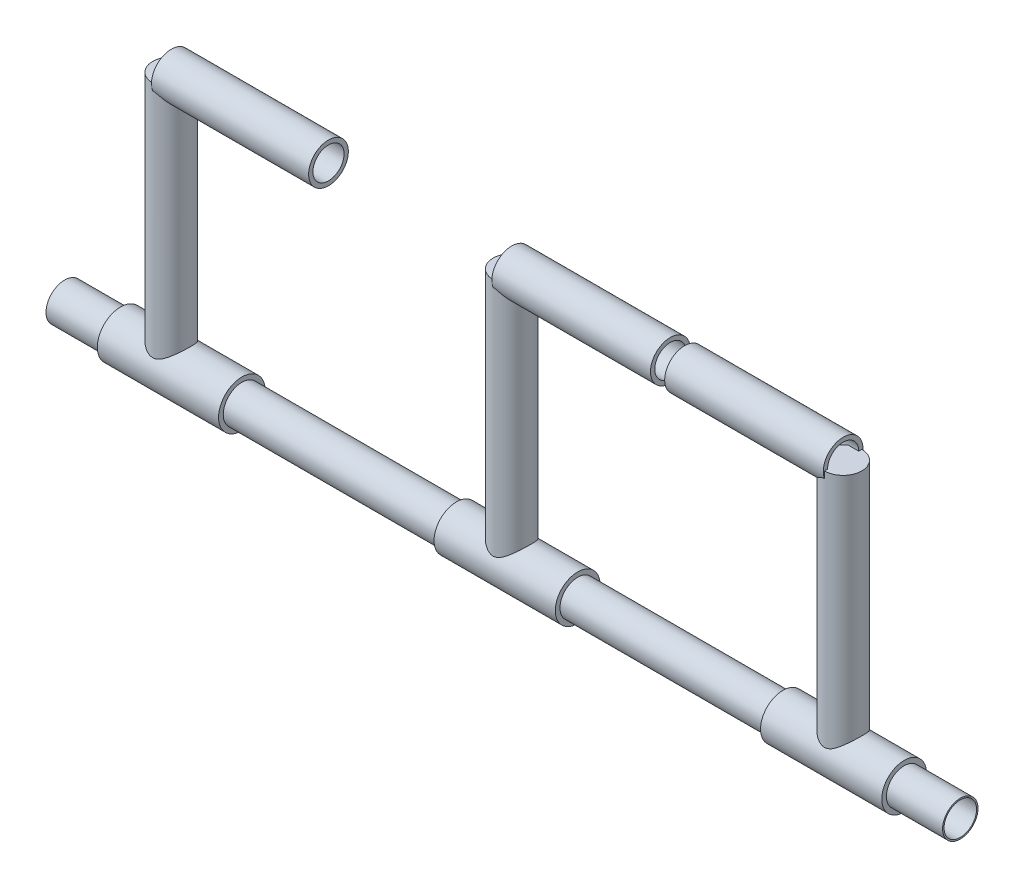
from build123d import *

# Parameters (mm, degrees)
SKETCH3_R                  = 8.721666083
CUT_EXTRUDE2_DEPTH         = 480
CUT_EXTRUDE2_DEPTH_BACK    = 500
SKETCH6_R                  = 10
BOSS_EXTRUDE1_DEPTH        = 135.069363488
SKETCH11_R                 = 10.65
SKETCH11_R_2               = 8.35
STRUCTURAL_MEMBER1_DEPTH   = 84.246035782
SKETCH13_R                 = 10
BOSS_EXTRUDE2_DEPTH        = 135
BOSS_EXTRUDE2_2_DEPTH      = 135
SKETCH12_R                 = 10.65
SKETCH12_R_2               = 8.35
STRUCTURAL_MEMBER2_DEPTH   = 85
SKETCH12_ON_SEGMENT_2_R    = 10.65
SKETCH12_ON_SEGMENT_2_R_2  = 8.35
STRUCTURAL_MEMBER2_2_DEPTH = 85


with BuildPart() as part:
    # Sketch1 → Revolve3 (revolve)
    with BuildSketch(Plane.XY, mode=Mode.PRIVATE) as revolve3_sk:
        Polygon((-57.171934505, 0), (-57.171934505, 10), (-27.171934505, 10), (-27.171934505, 12.5), (37.828065495, 12.5), (37.828065495, 10), (152.828065495, 10), (152.828065495, 12), (217.828065495, 12), (217.828065495, 9.5), (327.828065495, 9.5), (327.828065495, 12), (392.828065495, 12), (392.828065495, 9.5), (422.918888311, 9.5), (422.918888311, 0), align=None)
    revolve(revolve3_sk.sketch.rotate(Axis((-63.851816887, 0, 0), (1, 0, 0)), 90), axis=Axis((-63.851816887, 0, 0), (1, 0, 0)))

    # Sketch3 → Cut-Extrude2 (cut, two sides)
    with BuildSketch(Plane.ZY.offset(57.171934505)) as cut_extrude2_sk:
        with Locations(Location((0, 0, 0), (0, 0, 180))):
            Circle(SKETCH3_R)
    extrude(amount=CUT_EXTRUDE2_DEPTH, mode=Mode.SUBTRACT)
    extrude(cut_extrude2_sk.sketch, amount=-CUT_EXTRUDE2_DEPTH_BACK, mode=Mode.SUBTRACT)

    # Sketch6 → Boss-Extrude1 (add)
    with BuildSketch(Plane(origin=(0, 0, 0), x_dir=(1, 0, 0), z_dir=(0, 1, 0))):
        with Locations(Location((0, 0, 0), (0, 0, 90))):
            Circle(SKETCH6_R)
    extrude(amount=BOSS_EXTRUDE1_DEPTH)


with BuildPart() as body_2:
    # Sketch11 → Structural Member1 (new body)
    with BuildSketch(Plane(origin=(0, 135.069363488, 0), x_dir=(0, 0, -1), z_dir=(1, 0, 0))):
        Circle(SKETCH11_R)
        Circle(SKETCH11_R_2, mode=Mode.SUBTRACT)
    extrude(amount=STRUCTURAL_MEMBER1_DEPTH)


with BuildPart() as body_3:
    # Sketch13 → Boss-Extrude2 (new body)
    with BuildSketch(Plane(origin=(0, 0, 0), x_dir=(1, 0, 0), z_dir=(0, 1, 0))):
        with Locations(Location((182.476970148, 0, 0), (0, 0, 270))):
            Circle(SKETCH13_R)
    extrude(amount=BOSS_EXTRUDE2_DEPTH)


with BuildPart() as body_4:
    # Sketch13 → Boss-Extrude2 2 (new body)
    with BuildSketch(Plane(origin=(0, 0, 0), x_dir=(1, 0, 0), z_dir=(0, 1, 0))):
        with Locations(Location((360.111996239, 0, 0), (0, 0, 270))):
            Circle(SKETCH13_R)
    extrude(amount=BOSS_EXTRUDE2_2_DEPTH)


with BuildPart() as body_5:
    # Sketch12 → Structural Member2 (new body)
    with BuildSketch(Plane(origin=(182.476970148, 135, 0), x_dir=(0, 0, -1), z_dir=(1, 0, 0))):
        Circle(SKETCH12_R)
        Circle(SKETCH12_R_2, mode=Mode.SUBTRACT)
    extrude(amount=STRUCTURAL_MEMBER2_DEPTH)


with BuildPart() as body_6:
    # Sketch12 on segment 2 (carried to segment 2) → Structural Member2 2 (new body)
    with BuildSketch(Plane(origin=(275.111996239, 135, 0), x_dir=(0, 0, -1), z_dir=(1, 0, 0))):
        Circle(SKETCH12_ON_SEGMENT_2_R)
        Circle(SKETCH12_ON_SEGMENT_2_R_2, mode=Mode.SUBTRACT)
    extrude(amount=STRUCTURAL_MEMBER2_2_DEPTH)


solid = Compound([part.part, body_2.part, body_3.part, body_4.part, body_5.part, body_6.part])
